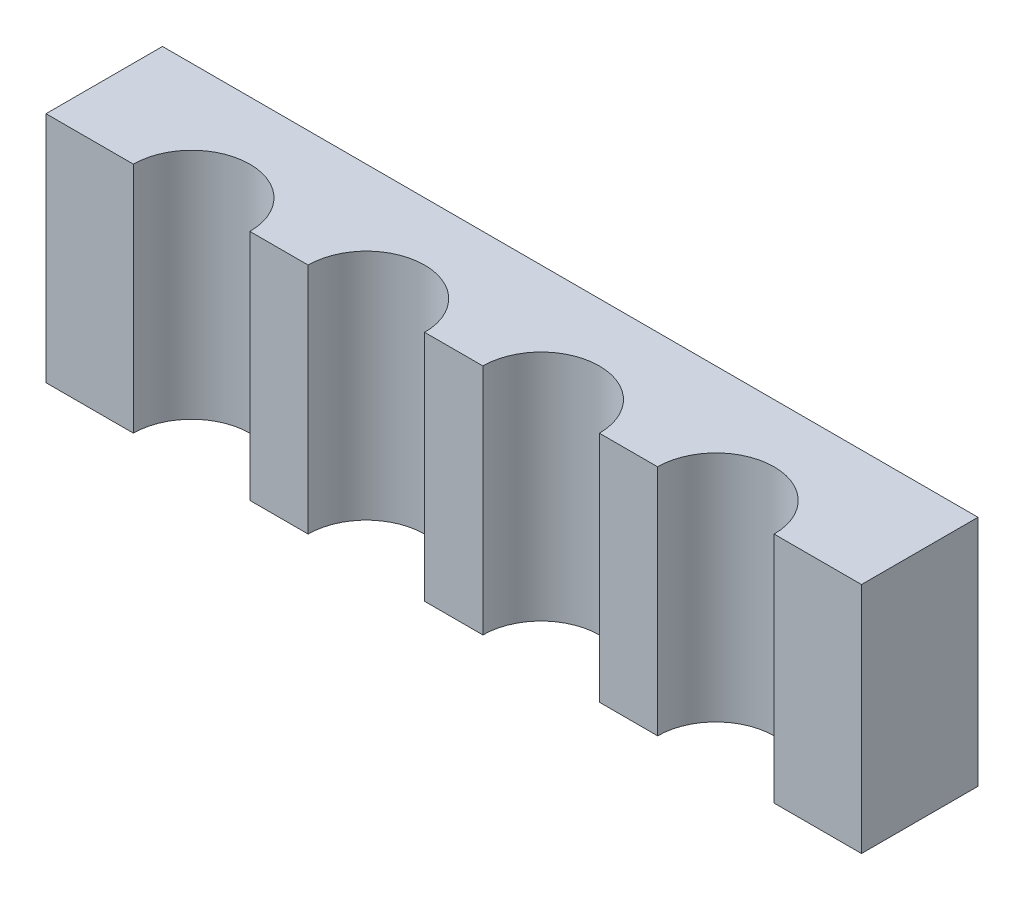
from build123d import *

# Parameters (mm, degrees)
BOSS_EXTRUDE1_DEPTH = 120


with BuildPart() as part:
    # Sketch1 → Boss-Extrude1 (new body)
    with BuildSketch(Plane(origin=(0, 0, 0), x_dir=(1, 0, 0), z_dir=(0, 1, 0))):
        with BuildLine():
            Line((-105, -30), (-75, -30))
            ThreePointArc((-75, -30), (-45, 0), (-15, -30))
            Line((-15, -30), (15, -30))
            ThreePointArc((15, -30), (45, 0), (75, -30))
            Line((75, -30), (105, -30))
            ThreePointArc((105, -30), (135, 0), (165, -30))
            Line((165, -30), (210, -30))
            Line((210, -30), (210, 30))
            Line((210, 30), (-210, 30))
            Line((-210, 30), (-210, -30))
            Line((-210, -30), (-165, -30))
            ThreePointArc((-165, -30), (-135, 0), (-105, -30))
        make_face()
    extrude(amount=BOSS_EXTRUDE1_DEPTH)


solid = part.part
